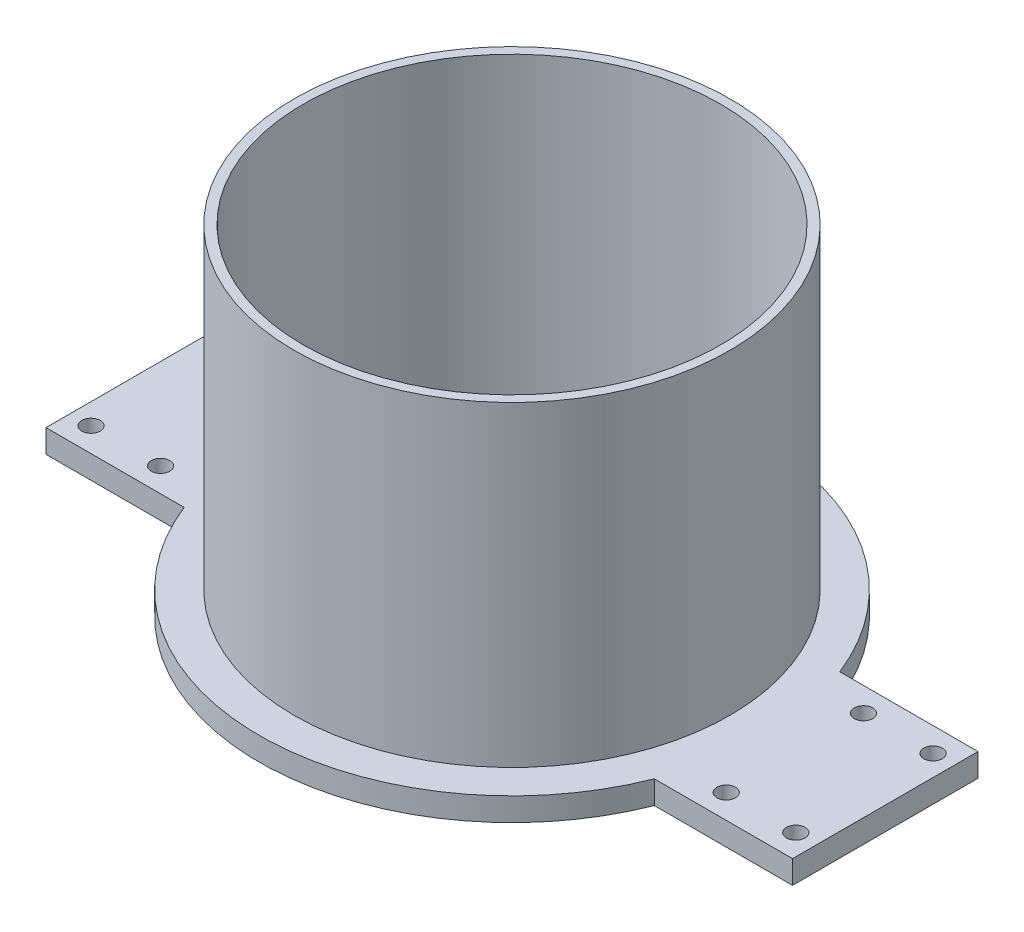
from build123d import *

# Parameters (mm, degrees)
SKETCH_1_R      = 45
SKETCH_1_R_2    = 2
EXTRUDE_1_DEPTH = 5
SKETCH_2_R      = 47
SKETCH_2_R_2    = 45
EXTRUDE_2_DEPTH = 68.18


with BuildPart() as part:
    # 草图1 → 凸台-拉伸1 (new body)
    with BuildSketch(Plane(origin=(0, 0, 0), x_dir=(1, 0, 0), z_dir=(0, 1, 0))):
        with BuildLine():
            Line((50.697633081, 20), (80.5, 20))
            Line((80.5, 20), (80.5, -20))
            Line((80.5, -20), (50.697633081, -20))
            ThreePointArc((50.697633081, -20), (0, -54.5), (-50.697633081, -20))
            Line((-50.697633081, -20), (-80.5, -20))
            Line((-80.5, -20), (-80.5, 20))
            Line((-80.5, 20), (-50.697633081, 20))
            ThreePointArc((-50.697633081, 20), (0, 54.5), (50.697633081, 20))
        make_face()
        Circle(SKETCH_1_R, mode=Mode.SUBTRACT)
        with Locations((76, -14.8)):
            Circle(SKETCH_1_R_2, mode=Mode.SUBTRACT)
        with Locations((61, -14.8)):
            Circle(SKETCH_1_R_2, mode=Mode.SUBTRACT)
        with Locations((76, 14.8)):
            Circle(SKETCH_1_R_2, mode=Mode.SUBTRACT)
        with Locations((61, 14.8)):
            Circle(SKETCH_1_R_2, mode=Mode.SUBTRACT)
        with Locations((-61, 14.8)):
            Circle(SKETCH_1_R_2, mode=Mode.SUBTRACT)
        with Locations((-76, 14.8)):
            Circle(SKETCH_1_R_2, mode=Mode.SUBTRACT)
        with Locations((-76, -14.8)):
            Circle(SKETCH_1_R_2, mode=Mode.SUBTRACT)
        with Locations((-61, -14.8)):
            Circle(SKETCH_1_R_2, mode=Mode.SUBTRACT)
    extrude(amount=EXTRUDE_1_DEPTH)

    # 草图2 → 凸台-拉伸2 (add)
    with BuildSketch(Plane(origin=(0, 5, 0), x_dir=(1, 0, 0), z_dir=(0, 1, 0))):
        Circle(SKETCH_2_R)
        Circle(SKETCH_2_R_2, mode=Mode.SUBTRACT)
    extrude(amount=EXTRUDE_2_DEPTH)


solid = part.part
